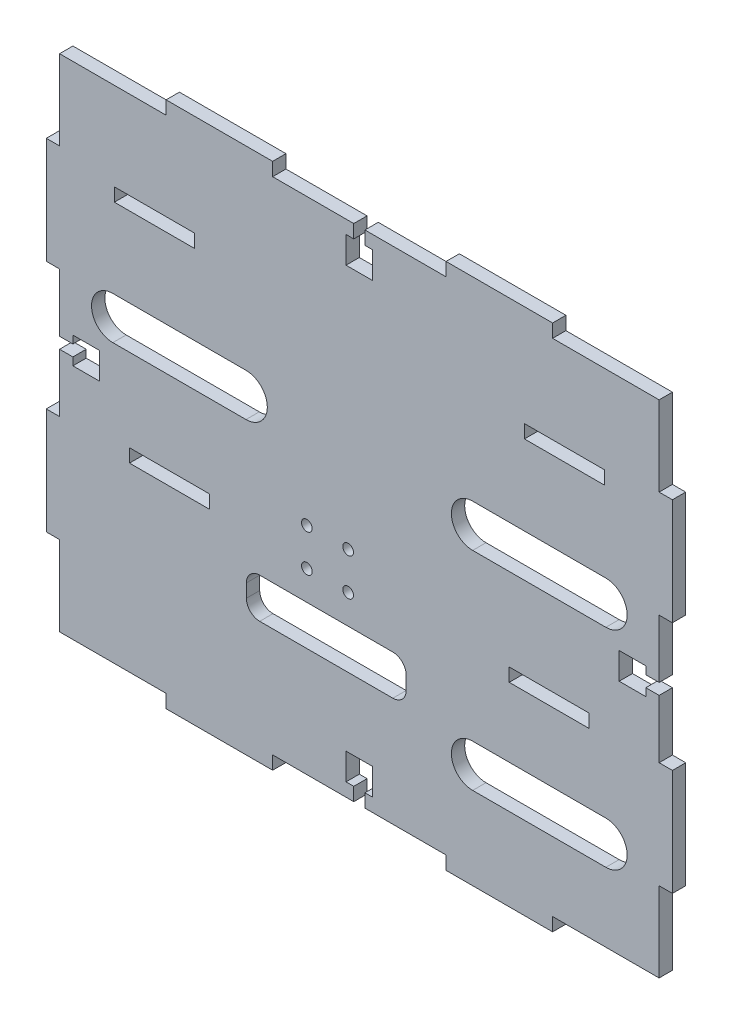
from build123d import *

# Parameters (mm, degrees)
SKETCH1_W           = 225.11
SKETCH1_H           = 188
BOSS_EXTRUDE1_DEPTH = 5
SKETCH2_R           = 2
CUT_EXTRUDE1_DEPTH  = 10
SKETCH3_W           = 40
SKETCH3_H           = 5
BOSS_EXTRUDE2_DEPTH = 5
SKETCH5_W           = 5
SKETCH5_H           = 40
SKETCH5_W_2         = 40
SKETCH5_H_2         = 5
BOSS_EXTRUDE3_DEPTH = 5
CUT_EXTRUDE2_DEPTH  = 5
CUT_EXTRUDE3_DEPTH  = 5
SKETCH8_W           = 30
SKETCH8_H           = 5
CUT_EXTRUDE4_DEPTH  = 5
SKETCH9_W           = 30.000010782
SKETCH9_H           = 5
CUT_EXTRUDE5_DEPTH  = 5
CUT_EXTRUDE6_DEPTH  = 15
BOSS_EXTRUDE4_DEPTH = 5


with BuildPart() as part:
    # Sketch1 → Boss-Extrude1 (new body)
    with BuildSketch(Plane.XY):
        Rectangle(SKETCH1_W, SKETCH1_H)
    extrude(amount=BOSS_EXTRUDE1_DEPTH)

    # Sketch2 → Cut-Extrude1 (cut)
    with BuildSketch(Plane.XY.offset(5)):
        with Locations((-19.714505863, -13)):
            Circle(SKETCH2_R)
        with Locations((-4.214505863, -13)):
            Circle(SKETCH2_R)
        with Locations((-4.214505863, -27)):
            Circle(SKETCH2_R)
        with Locations((-19.714505863, -27)):
            Circle(SKETCH2_R)
    extrude(amount=-CUT_EXTRUDE1_DEPTH, mode=Mode.SUBTRACT)

    # Sketch3 → Boss-Extrude2 (add)
    with BuildSketch(Plane.XZ.offset(94)):
        with Locations((-52.555, 2.5)):
            Rectangle(SKETCH3_W, SKETCH3_H)
        with Locations((52.555, 2.5)):
            Rectangle(SKETCH3_W, SKETCH3_H)
    extrude(amount=BOSS_EXTRUDE2_DEPTH)

    # Sketch5 → Boss-Extrude3 (add)
    with BuildSketch(Plane.XY.offset(5)):
        with Locations((115.055, -44)):
            Rectangle(SKETCH5_W, SKETCH5_H)
        with Locations((115.041030137, 44)):
            Rectangle(SKETCH5_W, SKETCH5_H)
        with Locations((52.555, 96.5)):
            Rectangle(SKETCH5_W_2, SKETCH5_H_2)
        with Locations((-52.555, 96.5)):
            Rectangle(SKETCH5_W_2, SKETCH5_H_2)
        with Locations((-115.041030137, 44)):
            Rectangle(SKETCH5_W, SKETCH5_H)
        with Locations((-115.055, -44)):
            Rectangle(SKETCH5_W, SKETCH5_H)
    extrude(amount=-BOSS_EXTRUDE3_DEPTH)

    # Sketch6 → Cut-Extrude2 (cut)
    with BuildSketch(Plane.XY.offset(5)):
        Polygon((112.555, -2.1), (107.555, -2.1), (107.555, -5), (97.555, -5), (97.555, 5), (107.555, 5), (107.555, 2.1), (112.555, 2.1), align=None)
        Polygon((2.1, -94), (2.1, -89), (5, -89), (5, -79), (-5, -79), (-5, -89), (-2.1, -89), (-2.1, -94), align=None)
        Polygon((-2.1, 94), (-2.1, 89), (-5, 89), (-5, 79), (5, 79), (5, 89), (2.1, 89), (2.1, 94), align=None)
        Polygon((-112.555, 2.1), (-107.555, 2.1), (-107.555, 5), (-97.555, 5), (-97.555, -5), (-107.555, -5), (-107.555, -2.1), (-112.555, -2.1), align=None)
    extrude(amount=-CUT_EXTRUDE2_DEPTH, mode=Mode.SUBTRACT)

    # Sketch7 → Cut-Extrude3 (cut)
    with BuildSketch(Plane.XY.offset(5)):
        with BuildLine():
            Line((12.585494137, -53), (-37.414505863, -53))
            ThreePointArc((-37.414505863, -53), (-40.950039769, -51.535533906), (-42.414505863, -48))
            Line((-42.414505863, -48), (-42.414505863, -43))
            ThreePointArc((-42.414505863, -43), (-40.950039769, -39.464466094), (-37.414505863, -38))
            Line((-37.414505863, -38), (12.585494137, -38))
            ThreePointArc((12.585494137, -38), (16.121028043, -39.464466094), (17.585494137, -43))
            Line((17.585494137, -43), (17.585494137, -48))
            ThreePointArc((17.585494137, -48), (16.121028043, -51.535533906), (12.585494137, -53))
        make_face()
    extrude(amount=-CUT_EXTRUDE3_DEPTH, mode=Mode.SUBTRACT)

    # Sketch8 → Cut-Extrude4 (cut)
    with BuildSketch(Plane.XY.offset(5)):
        with Locations((71.270247069, -23.5)):
            Rectangle(SKETCH8_W, SKETCH8_H)
        with Locations((-71.299246748, -23.5)):
            Rectangle(SKETCH8_W, SKETCH8_H)
    extrude(amount=-CUT_EXTRUDE4_DEPTH, mode=Mode.SUBTRACT)

    # Sketch9 → Cut-Extrude5 (cut)
    with BuildSketch(Plane(origin=(0, 0, 0), x_dir=(-1, 0, 0), z_dir=(0, 0, -1))):
        with Locations((76.984802428, 58.5)):
            Rectangle(SKETCH9_W, SKETCH9_H)
        with Locations((-76.984802428, 58.5)):
            Rectangle(SKETCH9_W, SKETCH9_H)
    extrude(amount=-CUT_EXTRUDE5_DEPTH, mode=Mode.SUBTRACT)

    # Sketch10 → Cut-Extrude6 (cut)
    with BuildSketch(Plane.XY.offset(5)):
        with BuildLine():
            Line((92.555, -68), (42.555, -68))
            ThreePointArc((42.555, -68), (34.555, -60), (42.555, -52))
            Line((42.555, -52), (92.555, -52))
            ThreePointArc((92.555, -52), (100.555, -60), (92.555, -68))
        make_face()
        with BuildLine():
            Line((92.555, 10.043404022), (42.555, 10.043404022))
            ThreePointArc((42.555, 10.043404022), (34.555, 18.043404022), (42.555, 26.043404022))
            Line((42.555, 26.043404022), (92.555, 26.043404022))
            ThreePointArc((92.555, 26.043404022), (100.555, 18.043404022), (92.555, 10.043404022))
        make_face()
        with BuildLine():
            Line((-92.555, 10.043404022), (-42.555, 10.043404022))
            ThreePointArc((-42.555, 10.043404022), (-34.555, 18.043404022), (-42.555, 26.043404022))
            Line((-42.555, 26.043404022), (-92.555, 26.043404022))
            ThreePointArc((-92.555, 26.043404022), (-100.555, 18.043404022), (-92.555, 10.043404022))
        make_face()
        with BuildLine():
            Line((-92.555, -68), (-42.555, -68))
            ThreePointArc((-42.555, -68), (-34.555, -60), (-42.555, -52))
            Line((-42.555, -52), (-92.555, -52))
            ThreePointArc((-92.555, -52), (-100.555, -60), (-92.555, -68))
        make_face()
    extrude(amount=-CUT_EXTRUDE6_DEPTH, mode=Mode.SUBTRACT)

    # Sketch11 → Boss-Extrude4 (add)
    with BuildSketch(Plane.XY.offset(5)):
        with BuildLine():
            Line((-92.555, -68), (-42.555, -68))
            ThreePointArc((-42.555, -68), (-34.555, -60), (-42.555, -52))
            Line((-42.555, -52), (-92.555, -52))
            ThreePointArc((-92.555, -52), (-100.555, -60), (-92.555, -68))
        make_face()
    extrude(amount=-BOSS_EXTRUDE4_DEPTH)


solid = part.part
